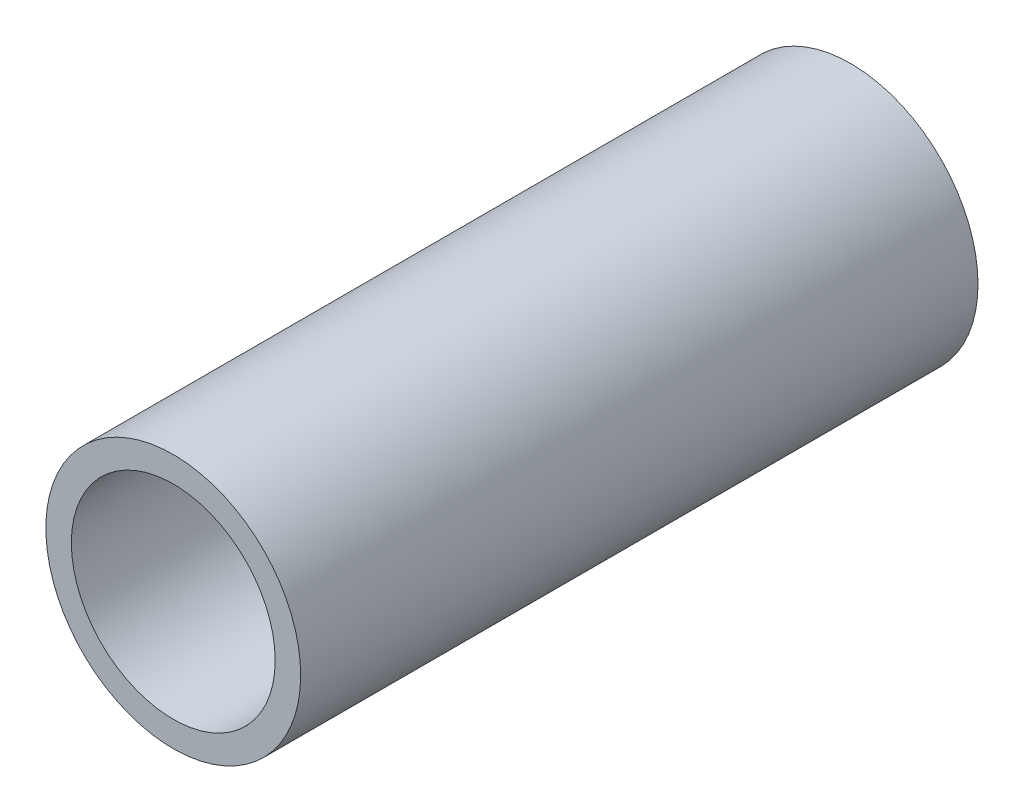
from build123d import *

# Parameters (mm, degrees)
SKETCH1_R           = 1.25
SKETCH1_R_2         = 1
BOSS_EXTRUDE1_DEPTH = 6.645


with BuildPart() as part:
    # Sketch1 → Boss-Extrude1 (new body)
    with BuildSketch(Plane.XY):
        Circle(SKETCH1_R)
        Circle(SKETCH1_R_2, mode=Mode.SUBTRACT)
    extrude(amount=BOSS_EXTRUDE1_DEPTH)


solid = part.part
